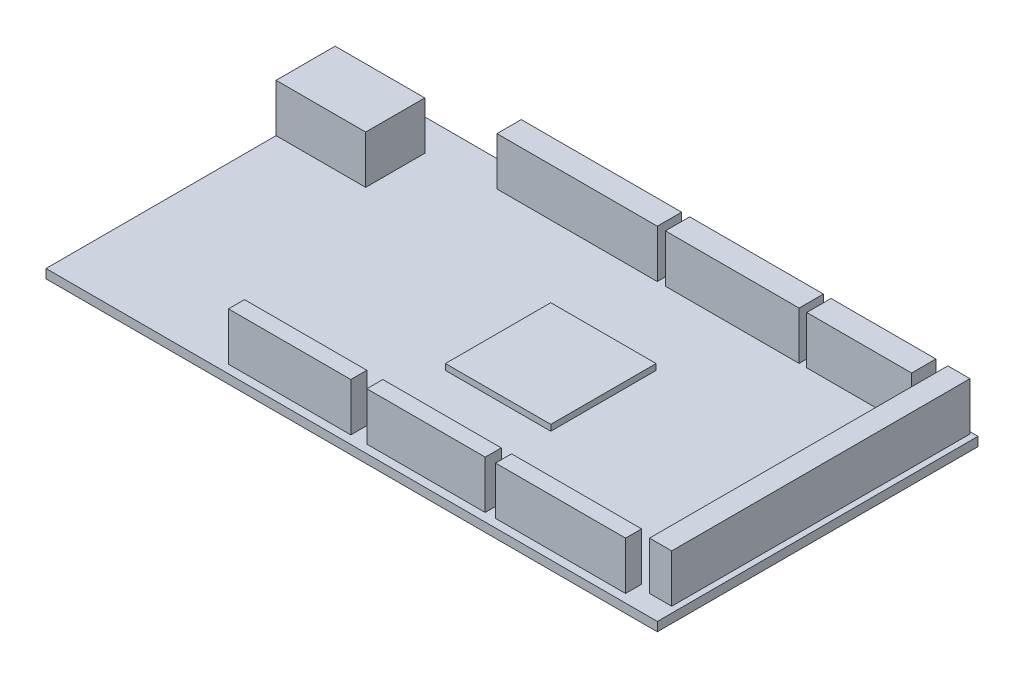
from build123d import *

# Parameters (mm, degrees)
SKETCH1_W           = 102
SKETCH1_H           = 53.5
BOSS_EXTRUDE1_DEPTH = 1.5
SKETCH2_W           = 14.952348819
SKETCH2_H           = 9.85729203
BOSS_EXTRUDE2_DEPTH = 8
SKETCH3_W           = 26.751318109
SKETCH3_H           = 4.056156536
SKETCH3_W_2         = 22.308860949
SKETCH3_W_3         = 17.497554299
SKETCH3_W_4         = 3.694182794
SKETCH3_H_2         = 49.772168178
SKETCH3_W_5         = 21.695691939
SKETCH3_H_3         = 2.671784729
SKETCH3_W_6         = 19.752122819
SKETCH3_W_7         = 20.420069002
BOSS_EXTRUDE3_DEPTH = 8
SKETCH4_W           = 17.576678325
SKETCH4_H           = 17.576678325
BOSS_EXTRUDE4_DEPTH = 1


with BuildPart() as part:
    # Sketch1 → Boss-Extrude1 (new body)
    with BuildSketch(Plane(origin=(0, 0, 0), x_dir=(1, 0, 0), z_dir=(0, 1, 0))):
        with Locations((51, 26.75)):
            Rectangle(SKETCH1_W, SKETCH1_H)
    extrude(amount=BOSS_EXTRUDE1_DEPTH)

    # Sketch2 → Boss-Extrude2 (add)
    with BuildSketch(Plane(origin=(0, 1.5, 0), x_dir=(-1, 0, 0), z_dir=(0, 1, 0))):
        with Locations((-7.47617441, -43.314315473)):
            Rectangle(SKETCH2_W, SKETCH2_H)
    extrude(amount=BOSS_EXTRUDE2_DEPTH)

    # Sketch3 → Boss-Extrude3 (add)
    with BuildSketch(Plane(origin=(0, 1.5, 0), x_dir=(-1, 0, 0), z_dir=(0, 1, 0))):
        with Locations((-39.507531481, -51.135226796)):
            Rectangle(SKETCH3_W, SKETCH3_H)
        with Locations((-65.389673188, -51.135226796)):
            Rectangle(SKETCH3_W_2, SKETCH3_H)
        with Locations((-86.563053436, -51.135226796)):
            Rectangle(SKETCH3_W_3, SKETCH3_H)
        with Locations((-99.154840724, -28.277220975)):
            Rectangle(SKETCH3_W_4, SKETCH3_H_2)
        with Locations((-84.463984616, -2.723190704)):
            Rectangle(SKETCH3_W_5, SKETCH3_H_3)
        with Locations((-62.02250134, -2.723190704)):
            Rectangle(SKETCH3_W_6, SKETCH3_H_3)
        with Locations((-39.2646207, -2.723190704)):
            Rectangle(SKETCH3_W_7, SKETCH3_H_3)
    extrude(amount=BOSS_EXTRUDE3_DEPTH)

    # Sketch4 → Boss-Extrude4 (add)
    with BuildSketch(Plane(origin=(0, 1.5, 0), x_dir=(-1, 0, 0), z_dir=(0, 1, 0))):
        with Locations((-56.842771916, -27.377738511)):
            Rectangle(SKETCH4_W, SKETCH4_H)
    extrude(amount=BOSS_EXTRUDE4_DEPTH)


solid = part.part
